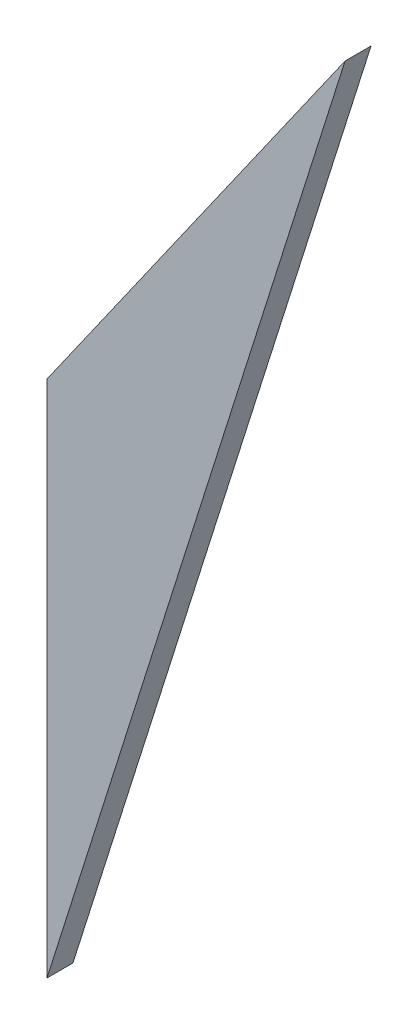
from build123d import *

# Parameters (mm, degrees)
BOSS_EXTRU_1_DEPTH = 3


with BuildPart() as part:
    # Esquisse1 → Boss.-Extru.1 (new body)
    with BuildSketch(Plane.XY):
        Polygon((-195.517439878, 119.153277946), (-230, 70.051821272), (-230, 10.051821272), align=None)
    extrude(amount=-BOSS_EXTRU_1_DEPTH)


solid = part.part
